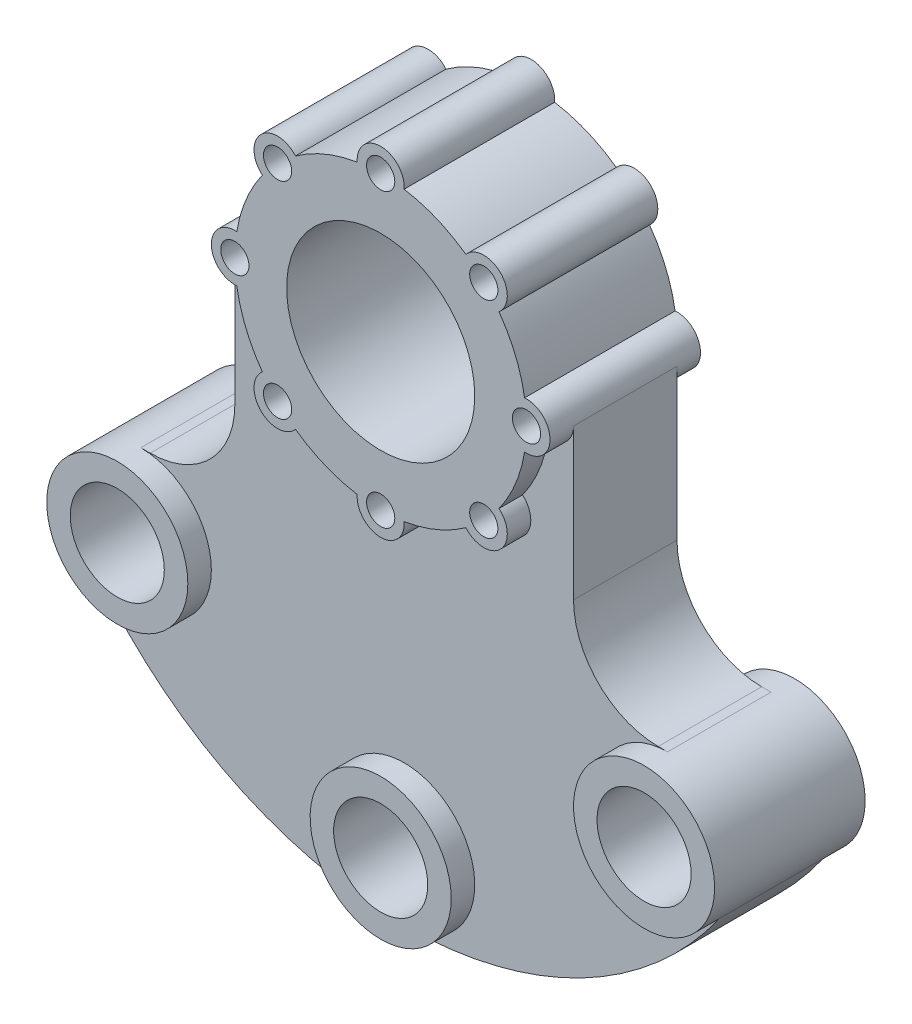
from build123d import *

# Parameters (mm, degrees)
SKETCH1_R             = 20
SKETCH1_R_2           = 3
BOSS_EXTRUDE5_DEPTH   = 16
SKETCH1_R_3           = 15
SKETCH1_R_4           = 10
BOSS_EXTRUDE5_2_DEPTH = 16
BOSS_EXTRUDE5_3_DEPTH = 16
BOSS_EXTRUDE5_4_DEPTH = 16
BOSS_EXTRUDE6_START   = -5
BOSS_EXTRUDE6_DEPTH   = 22
SKETCH3_R             = 10
CUT_EXTRUDE1_DEPTH    = 28
FILLET1_R             = 18


with BuildPart() as part:
    # Sketch1 → Boss-Extrude5 (new body, symmetric)
    with BuildSketch(Plane.XY):
        with BuildLine():
            ThreePointArc((-18.111168286, 25.159204743), (-25.455844123, 25.455844123), (-25.159204743, 18.111168286))
            ThreePointArc((-25.159204743, 18.111168286), (-28.640265508, 11.863186403), (-30.596774194, 4.983714373))
            ThreePointArc((-30.596774194, 4.983714373), (-36, 0), (-30.596774194, -4.983714373))
            ThreePointArc((-30.596774194, -4.983714373), (-28.640265508, -11.863186403), (-25.159204743, -18.111168286))
            ThreePointArc((-25.159204743, -18.111168286), (-25.455844123, -25.455844123), (-18.111168286, -25.159204743))
            ThreePointArc((-18.111168286, -25.159204743), (-11.863186403, -28.640265508), (-4.983714373, -30.596774194))
            ThreePointArc((-4.983714373, -30.596774194), (0, -36), (4.983714373, -30.596774194))
            ThreePointArc((4.983714373, -30.596774194), (11.863186403, -28.640265508), (18.111168286, -25.159204743))
            ThreePointArc((18.111168286, -25.159204743), (25.455844123, -25.455844123), (25.159204743, -18.111168286))
            ThreePointArc((25.159204743, -18.111168286), (28.640265508, -11.863186403), (30.596774194, -4.983714373))
            ThreePointArc((30.596774194, -4.983714373), (36, 0), (30.596774194, 4.983714373))
            ThreePointArc((30.596774194, 4.983714373), (28.640265508, 11.863186403), (25.159204743, 18.111168286))
            ThreePointArc((25.159204743, 18.111168286), (25.455844123, 25.455844123), (18.111168286, 25.159204743))
            ThreePointArc((18.111168286, 25.159204743), (11.863186403, 28.640265508), (4.983714373, 30.596774194))
            ThreePointArc((4.983714373, 30.596774194), (0, 36), (-4.983714373, 30.596774194))
            ThreePointArc((-4.983714373, 30.596774194), (-11.863186403, 28.640265508), (-18.111168286, 25.159204743))
        make_face()
        Circle(SKETCH1_R, mode=Mode.SUBTRACT)
        with Locations((31, 0)):
            Circle(SKETCH1_R_2, mode=Mode.SUBTRACT)
        with Locations((21.920310217, -21.920310217)):
            Circle(SKETCH1_R_2, mode=Mode.SUBTRACT)
        with Locations((0, -31)):
            Circle(SKETCH1_R_2, mode=Mode.SUBTRACT)
        with Locations((-21.920310217, -21.920310217)):
            Circle(SKETCH1_R_2, mode=Mode.SUBTRACT)
        with Locations((-31, 0)):
            Circle(SKETCH1_R_2, mode=Mode.SUBTRACT)
        with Locations((-21.920310217, 21.920310217)):
            Circle(SKETCH1_R_2, mode=Mode.SUBTRACT)
        with Locations((0, 31)):
            Circle(SKETCH1_R_2, mode=Mode.SUBTRACT)
        with Locations((21.920310217, 21.920310217)):
            Circle(SKETCH1_R_2, mode=Mode.SUBTRACT)
    extrude(amount=BOSS_EXTRUDE5_DEPTH, both=True)



with BuildPart() as body_2:
    # Sketch1 → Boss-Extrude5 2 (new body, symmetric)
    with BuildSketch(Plane.XY):
        with Locations((-56, -65)):
            Circle(SKETCH1_R_3)
        with Locations((-56, -65)):
            Circle(SKETCH1_R_4, mode=Mode.SUBTRACT)
    extrude(amount=BOSS_EXTRUDE5_2_DEPTH, both=True)


with BuildPart() as body_3:
    # Sketch1 → Boss-Extrude5 3 (new body, symmetric)
    with BuildSketch(Plane.XY):
        with Locations((0, -95)):
            Circle(SKETCH1_R_3)
        with Locations((0, -95)):
            Circle(SKETCH1_R_4, mode=Mode.SUBTRACT)
    extrude(amount=BOSS_EXTRUDE5_3_DEPTH, both=True)


with BuildPart() as body_4:
    # Sketch1 → Boss-Extrude5 4 (new body, symmetric)
    with BuildSketch(Plane.XY):
        with Locations((56, -65)):
            Circle(SKETCH1_R_3)
        with Locations((56, -65)):
            Circle(SKETCH1_R_4, mode=Mode.SUBTRACT)
    extrude(amount=BOSS_EXTRUDE5_4_DEPTH, both=True)


with BuildPart() as part_1:
    add(part.part)

    add(body_2.part)  # Boss-Extrude6 merges body 2

    add(body_3.part)  # Boss-Extrude6 merges body 3

    add(body_4.part)  # Boss-Extrude6 merges body 4
    # Sketch2 → Boss-Extrude6 (add)
    with BuildSketch(Plane.XY.offset(16).offset(BOSS_EXTRUDE6_START)):
        with BuildLine():
            ThreePointArc((-30.596774194, -4.983714373), (-34.389975735, -3.675331892), (-36, 0))
            Line((-36, 0), (-36, -50))
            Line((-36, -50), (-56, -50))
            ThreePointArc((-56, -50), (-69.390946307, -58.241112739), (-68.06771952, -73.9089924))
            ThreePointArc((-68.06771952, -73.9089924), (-0.88009942, -109.996258841), (66.9897647, -75.209068118))
            ThreePointArc((66.9897647, -75.209068118), (69.750200394, -59.005670253), (56, -50))
            Line((56, -50), (36, -50))
            Line((36, -50), (36, 0))
            ThreePointArc((36, 0), (34.389975735, -3.675331892), (30.596774194, -4.983714373))
            ThreePointArc((30.596774194, -4.983714373), (28.640265508, -11.863186403), (25.159204743, -18.111168286))
            ThreePointArc((25.159204743, -18.111168286), (25.455844123, -25.455844123), (18.111168286, -25.159204743))
            ThreePointArc((18.111168286, -25.159204743), (11.863186403, -28.640265508), (4.983714373, -30.596774194))
            ThreePointArc((4.983714373, -30.596774194), (0, -36), (-4.983714373, -30.596774194))
            ThreePointArc((-4.983714373, -30.596774194), (-11.863186403, -28.640265508), (-18.111168286, -25.159204743))
            ThreePointArc((-18.111168286, -25.159204743), (-25.455844123, -25.455844123), (-25.159204743, -18.111168286))
            ThreePointArc((-25.159204743, -18.111168286), (-28.640265508, -11.863186403), (-30.596774194, -4.983714373))
        make_face()
    extrude(amount=-BOSS_EXTRUDE6_DEPTH)

    # Sketch3 → Cut-Extrude1 (cut, through all)
    with BuildSketch(Plane.XY.offset(11)):
        with Locations((-56, -65)):
            Circle(SKETCH3_R)
        with Locations((0, -95)):
            Circle(SKETCH3_R)
        with Locations((56, -65)):
            Circle(SKETCH3_R)
    extrude(amount=-CUT_EXTRUDE1_DEPTH, mode=Mode.SUBTRACT)

    # Fillet1
    fillet1_edges = [part_1.edges().sort_by_distance(p)[0] for p in [
        (-36, -50, 0),
        (36, -50, 0),
    ]]
    fillet(fillet1_edges, radius=FILLET1_R)


solid = part_1.part
